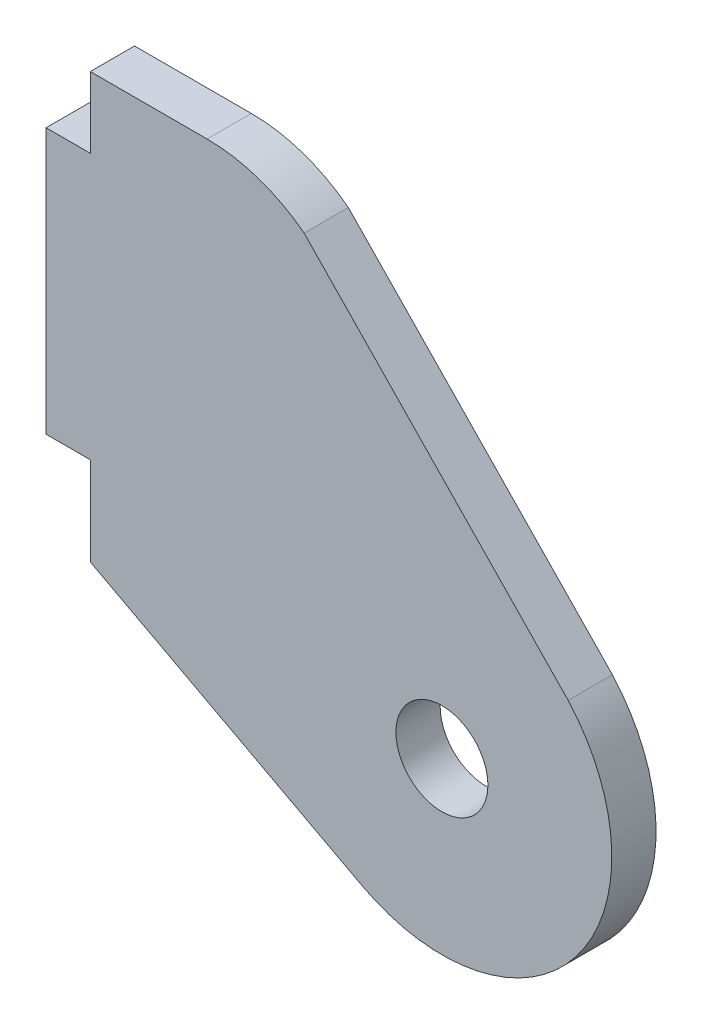
from build123d import *

# Parameters (mm, degrees)
BOSS_EXTRUDE1_DEPTH      = 3.175
M6_CLEARANCE_HOLE1_D     = 6.6
M6_CLEARANCE_HOLE1_DEPTH = 3.302
M6_CLEARANCE_HOLE1_TIP   = 1.982840043


with BuildPart() as part:
    # Sketch1 → Boss-Extrude1 (new body)
    with BuildSketch(Plane.XY):
        with BuildLine():
            Line((-79.409543338, -48.870574021), (-79.409543338, -29.820574021))
            Line((-79.409543338, -29.820574021), (-76.234543338, -29.820574021))
            Line((-76.234543338, -29.820574021), (-76.234543338, -24.740574021))
            Line((-76.234543338, -24.740574021), (-67.852543338, -24.740574021))
            ThreePointArc((-67.852543338, -24.740574021), (-64.175656813, -25.348124877), (-60.889653149, -27.10618986))
            Line((-60.889653149, -27.10618986), (-41.938948425, -46.672019211))
            ThreePointArc((-41.938948425, -46.672019211), (-41.391943029, -62.336204271), (-56.723167431, -65.594956616))
            Line((-56.723167431, -65.594956616), (-76.234543338, -55.220574021))
            Line((-76.234543338, -55.220574021), (-76.234543338, -48.870574021))
            Line((-76.234543338, -48.870574021), (-79.409543338, -48.870574021))
        make_face()
    extrude(amount=BOSS_EXTRUDE1_DEPTH)

    # M6 Clearance Hole1
    with Locations(Plane(origin=(0, 0, 0), x_dir=(-1, 0, 0), z_dir=(0, 0, -1))):
        with Locations((50.999370137, -54.830059564)):
            Hole(M6_CLEARANCE_HOLE1_D / 2, depth=M6_CLEARANCE_HOLE1_DEPTH)
            with Locations((0, 0, -(M6_CLEARANCE_HOLE1_DEPTH + M6_CLEARANCE_HOLE1_TIP / 2))):  # 118° drill point
                Cone(0, M6_CLEARANCE_HOLE1_D / 2, M6_CLEARANCE_HOLE1_TIP, mode=Mode.SUBTRACT)


solid = part.part
